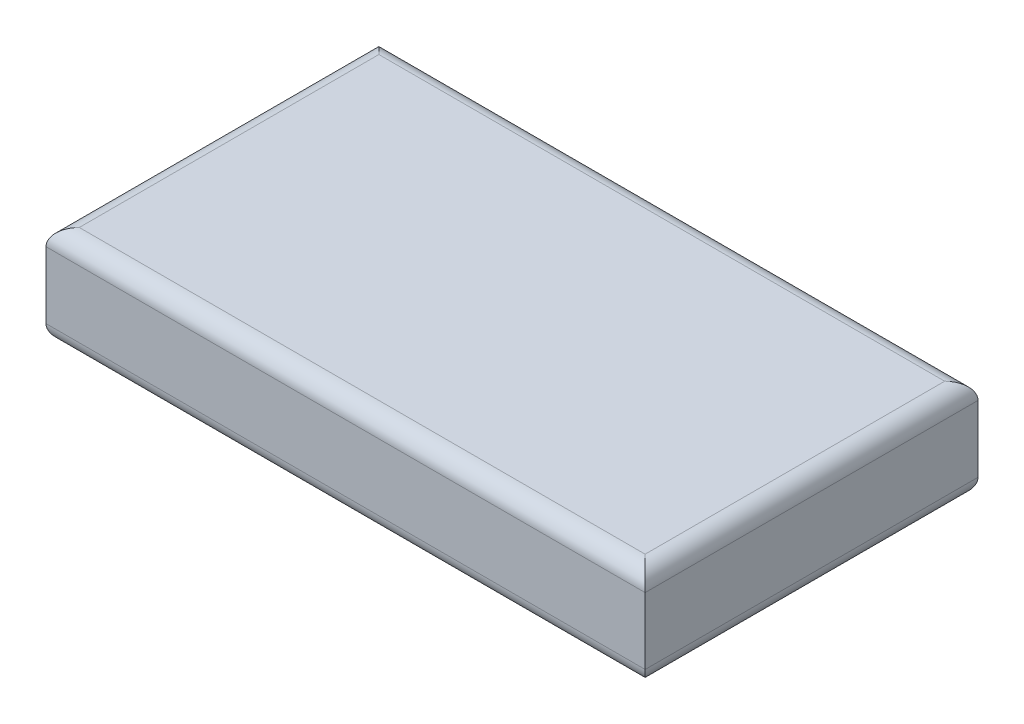
from build123d import *

# Parameters (mm, degrees)
SKETCH1_W           = 36
SKETCH1_H           = 20
BOSS_EXTRUDE1_DEPTH = 6
FILLET1_R           = 1


with BuildPart() as part:
    # Sketch1 → Boss-Extrude1 (new body)
    with BuildSketch(Plane(origin=(0, 0, 0), x_dir=(1, 0, 0), z_dir=(0, 1, 0))):
        Rectangle(SKETCH1_W, SKETCH1_H)
    extrude(amount=BOSS_EXTRUDE1_DEPTH)

    # Fillet1
    fillet1_edges = [part.edges().sort_by_distance(p)[0] for p in [
        (-18, 6, 0),
        (0, 6, 10),
        (18, 6, 0),
        (0, 0, 10),
        (-18, 0, 0),
        (0, 0, -10),
        (18, 0, 0),
        (0, 6, -10),
    ]]
    fillet(fillet1_edges, radius=FILLET1_R)


solid = part.part
